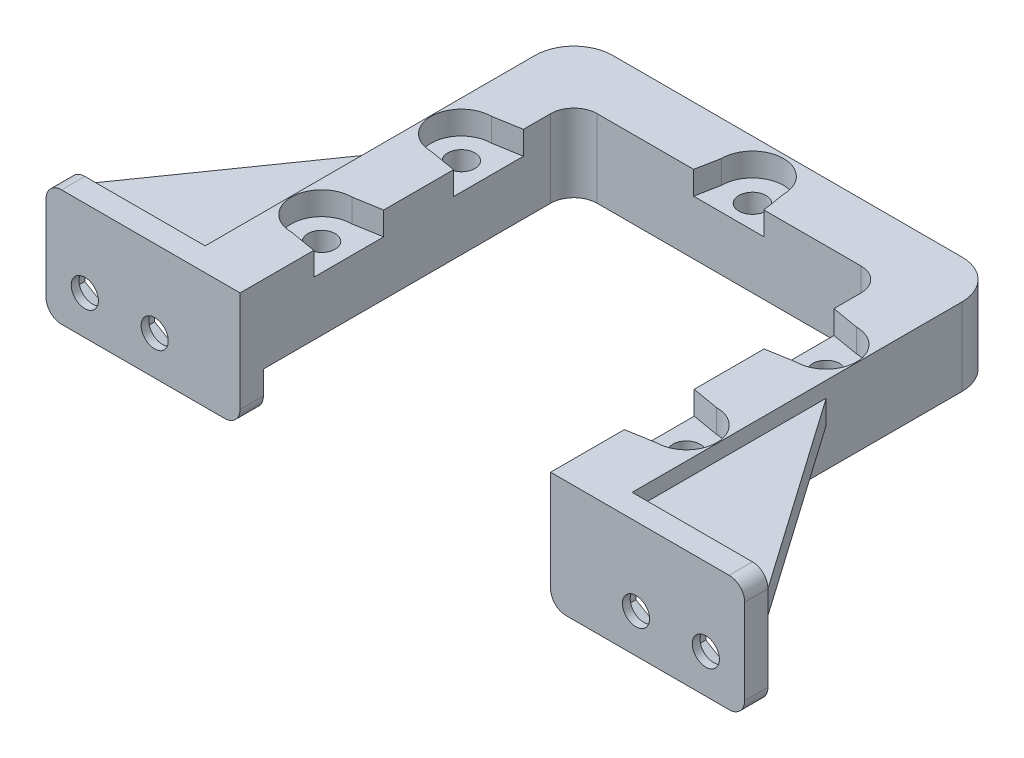
from build123d import *

# Parameters (mm, degrees)
BOSS_EXTRUDE1_DEPTH  = 10
SKETCH2_R            = 1.75
CUT_EXTRUDE1_DEPTH   = 15.5
CUT_EXTRUDE2_DEPTH   = 3
CUT_EXTRUDE7_DEPTH   = 3
SKETCH9_W            = 25
SKETCH9_H            = 15
BOSS_EXTRUDE2_DEPTH  = 3
SKETCH11_W           = 17.5
SKETCH11_H           = 3
BOSS_EXTRUDE4_DEPTH  = 25
CUT_EXTRUDE9_DEPTH   = 25
FILLET2_R            = 2
SKETCH14_R           = 1.75
CUT_EXTRUDE10_DEPTH  = 4
CUT_EXTRUDE11_DEPTH  = 2
FILLET2_OF_MIRROR1_R = 2


with BuildPart() as part:
    # Sketch1 → Boss-Extrude1 (new body)
    with BuildSketch(Plane(origin=(0, 0, 0), x_dir=(1, 0, 0), z_dir=(0, 1, 0))):
        with BuildLine():
            Line((-20, -20), (-27.5, -20))
            Line((-27.5, -20), (-27.5, 22.5))
            ThreePointArc((-27.5, 22.5), (-26.035533906, 26.035533906), (-22.5, 27.5))
            Line((-22.5, 27.5), (22.5, 27.5))
            ThreePointArc((22.5, 27.5), (26.035533906, 26.035533906), (27.5, 22.5))
            Line((27.5, 22.5), (27.5, -20))
            Line((27.5, -20), (20, -20))
            Line((20, -20), (20, 17))
            ThreePointArc((20, 17), (19.121320344, 19.121320344), (17, 20))
            Line((17, 20), (-17, 20))
            ThreePointArc((-17, 20), (-19.121320344, 19.121320344), (-20, 17))
            Line((-20, 17), (-20, -20))
        make_face()
    extrude(amount=BOSS_EXTRUDE1_DEPTH)

    # Sketch2 → Cut-Extrude1 (cut)
    with BuildSketch(Plane(origin=(0, 10, 0), x_dir=(1, 0, 0), z_dir=(0, 1, 0))):
        with Locations((-23.5, -9)):
            Circle(SKETCH2_R)
        with Locations((23.5, -9)):
            Circle(SKETCH2_R)
        with Locations((0, 23)):
            Circle(SKETCH2_R)
        with Locations((-23.5, 9)):
            Circle(SKETCH2_R)
        with Locations((23.5, 9)):
            Circle(SKETCH2_R)
    extrude(amount=-CUT_EXTRUDE1_DEPTH, mode=Mode.SUBTRACT)

    # Sketch3 → Cut-Extrude2 (cut)
    with BuildSketch(Plane.XZ):
        Polygon((-20.6, 7.325684219), (-20.6, 10.674315781), (-23.5, 12.348631561), (-26.4, 10.674315781), (-26.4, 7.325684219), (-23.5, 5.651368439), align=None)
        Polygon((23.4996681, 5.651368455), (26.399834036, 7.325396794), (26.400165936, 10.674028339), (23.5003319, 12.348631545), (20.600165964, 10.674603206), (20.599834064, 7.325971661), align=None)
        Polygon((3.348631561, -23), (1.674315781, -20.1), (-1.674315781, -20.1), (-3.348631561, -23), (-1.674315781, -25.9), (1.674315781, -25.9), align=None)
        Polygon((-23.4996681, -5.651368455), (-26.399834036, -7.325396794), (-26.400165936, -10.674028339), (-23.5003319, -12.348631545), (-20.600165964, -10.674603206), (-20.599834064, -7.325971661), align=None)
        Polygon((23.4996681, -5.651368455), (20.599834064, -7.325971661), (20.600165964, -10.674603206), (23.5003319, -12.348631545), (26.400165936, -10.674028339), (26.399834036, -7.325396794), align=None)
    extrude(amount=-CUT_EXTRUDE2_DEPTH, mode=Mode.SUBTRACT)

    # Sketch8 → Cut-Extrude7 (cut)
    with BuildSketch(Plane(origin=(0, 10, 0), x_dir=(1, 0, 0), z_dir=(0, 1, 0))):
        with BuildLine():
            Line((-4, 23), (-4.57455059, 20))
            Line((-4.57455059, 20), (4.478329848, 20))
            Line((4.478329848, 20), (4, 23))
            ThreePointArc((4, 23), (0, 27), (-4, 23))
        make_face()
        with BuildLine():
            Line((23.5, 12.9), (20, 13.5))
            Line((20, 13.5), (20, 4.5))
            Line((20, 4.5), (23.5, 5.1))
            ThreePointArc((23.5, 5.1), (27.4, 9), (23.5, 12.9))
        make_face()
        with BuildLine():
            Line((23.5, -5.1), (20, -4.5))
            Line((20, -4.5), (20, -13.5))
            Line((20, -13.5), (23.5, -12.9))
            ThreePointArc((23.5, -12.9), (27.4, -9), (23.5, -5.1))
        make_face()
        with BuildLine():
            Line((-23.5, -12.9), (-20, -13.5))
            Line((-20, -13.5), (-20, -4.5))
            Line((-20, -4.5), (-23.5, -5.1))
            ThreePointArc((-23.5, -5.1), (-27.4, -9), (-23.5, -12.9))
        make_face()
        with BuildLine():
            Line((-23.5, 12.9), (-20, 13.5))
            Line((-20, 13.5), (-20, 4.5))
            Line((-20, 4.5), (-23.5, 5.1))
            ThreePointArc((-23.5, 5.1), (-27.4, 9), (-23.5, 12.9))
        make_face()
    extrude(amount=-CUT_EXTRUDE7_DEPTH, mode=Mode.SUBTRACT)

    # Sketch9 → Boss-Extrude2 (add)
    with BuildSketch(Plane.XY.offset(20)):
        with Locations((-32.5, 2.5)):
            Rectangle(SKETCH9_W, SKETCH9_H)
    boss_extrude2 = extrude(amount=BOSS_EXTRUDE2_DEPTH)

    # Sketch11 → Boss-Extrude4 (add)
    with BuildSketch(Plane(origin=(0, 0, 20), x_dir=(-1, 0, 0), z_dir=(0, 0, -1))):
        with Locations((36.25, 6.5)):
            Rectangle(SKETCH11_W, SKETCH11_H)
    boss_extrude4 = extrude(amount=BOSS_EXTRUDE4_DEPTH)

    # Sketch13 → Cut-Extrude9 (cut)
    with BuildSketch(Plane.XZ.offset(-5)):
        Polygon((-45, 20), (-27.5, -5), (-45, -5), align=None)
    cut_extrude9 = extrude(amount=-CUT_EXTRUDE9_DEPTH, mode=Mode.SUBTRACT)

    # Fillet2
    fillet2_edges = [part.edges().sort_by_distance(p)[0] for p in [
        (-45, 10, 21.5),
        (-45, -5, 21.5),
        (-20, -5, 21.5),
    ]]
    fillet(fillet2_edges, radius=FILLET2_R)

    # Sketch14 → Cut-Extrude10 (cut, through all)
    with BuildSketch(Plane(origin=(0, 0, 20), x_dir=(-1, 0, 0), z_dir=(0, 0, -1))):
        with Locations((40, 0)):
            Circle(SKETCH14_R)
        with Locations((31, 0)):
            Circle(SKETCH14_R)
    cut_extrude10 = extrude(amount=-CUT_EXTRUDE10_DEPTH, mode=Mode.SUBTRACT)

    # Sketch15 → Cut-Extrude11 (cut)
    with BuildSketch(Plane(origin=(0, 0, 20), x_dir=(-1, 0, 0), z_dir=(0, 0, -1))):
        Polygon((31, 3.464101615), (28, 1.732050808), (28, -1.732050808), (31, -3.464101615), (34, -1.732050808), (34, 1.732050808), align=None)
        Polygon((40, 3.464101615), (37, 1.732050808), (37, -1.732050808), (40, -3.464101615), (43, -1.732050808), (43, 1.732050808), align=None)
    cut_extrude11 = extrude(amount=-CUT_EXTRUDE11_DEPTH, mode=Mode.SUBTRACT)

    # Mirror1: Boss-Extrude2, Boss-Extrude4, Cut-Extrude9, Cut-Extrude10, Cut-Extrude11 across plane
    add(boss_extrude2.mirror(Plane(origin=(0, 0, 0), x_dir=(0, 0, 1), z_dir=(1, 0, 0))))
    add(boss_extrude4.mirror(Plane(origin=(0, 0, 0), x_dir=(0, 0, 1), z_dir=(1, 0, 0))))
    add(cut_extrude9.mirror(Plane(origin=(0, 0, 0), x_dir=(0, 0, 1), z_dir=(1, 0, 0))), mode=Mode.SUBTRACT)
    add(cut_extrude10.mirror(Plane(origin=(0, 0, 0), x_dir=(0, 0, 1), z_dir=(1, 0, 0))), mode=Mode.SUBTRACT)
    add(cut_extrude11.mirror(Plane(origin=(0, 0, 0), x_dir=(0, 0, 1), z_dir=(1, 0, 0))), mode=Mode.SUBTRACT)

    # Fillet2 of Mirror1
    fillet2_of_mirror1_edges = [part.edges().sort_by_distance(p)[0] for p in [
        (45, 10, 21.5),
        (45, -5, 21.5),
        (20, -5, 21.5),
    ]]
    fillet(fillet2_of_mirror1_edges, radius=FILLET2_OF_MIRROR1_R)


solid = part.part
